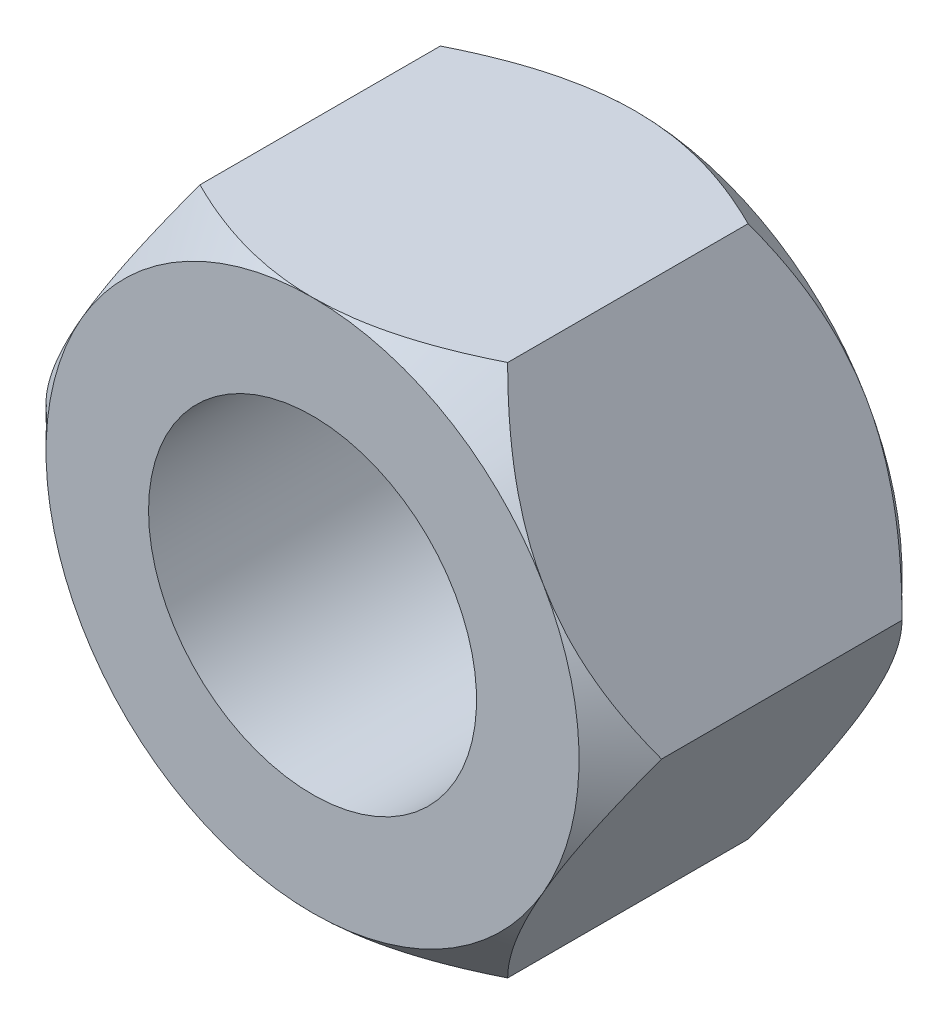
from build123d import *

# Parameters (mm, degrees)
SKETCH1_R           = 12.7
BOSS_EXTRUDE1_DEPTH = 25.003125


with BuildPart() as part:
    # Sketch1 → Boss-Extrude1 (new body)
    with BuildSketch(Plane.XY):
        Polygon((-11.91506618, 20.6375), (-23.830132361, 0), (-11.91506618, -20.6375), (11.91506618, -20.6375), (23.830132361, 0), (11.91506618, 20.6375), align=None)
        with Locations(Location((0, 0, 0), (0, 0, 180))):
            Circle(SKETCH1_R, mode=Mode.SUBTRACT)
    extrude(amount=BOSS_EXTRUDE1_DEPTH)

    # Cut-Sweep1: sweep along a curve in space
    with BuildLine() as cut_sweep1_path:
        ThreePointArc((12.7, 0, 25.003125), (8.980256121, 8.980256121, 25.003125), (0, 12.7, 25.003125))
        ThreePointArc((0, 12.7, 25.003125), (-8.980256121, 8.980256121, 25.003125), (-12.7, 0, 25.003125))
        ThreePointArc((-12.7, 0, 25.003125), (-8.980256121, -8.980256121, 25.003125), (0, -12.7, 25.003125))
        ThreePointArc((0, -12.7, 25.003125), (8.980256121, -8.980256121, 25.003125), (12.7, 0, 25.003125))
    # Sketch2 → Cut-Sweep1 (sweep, cut)
    with BuildSketch(Plane(origin=(0, 0, 0), x_dir=(0, 0, -1), z_dir=(1, 0, 0))):
        Polygon((-25.003125, 20.6375), (-18.653125, 26.9875), (-31.353125, 26.9875), (-31.353125, 14.2875), align=None)
        Polygon((6.35, 14.2875), (0, 20.6375), (-6.35, 26.9875), (6.35, 26.9875), align=None)
    sweep(path=cut_sweep1_path.line, mode=Mode.SUBTRACT)


solid = part.part
